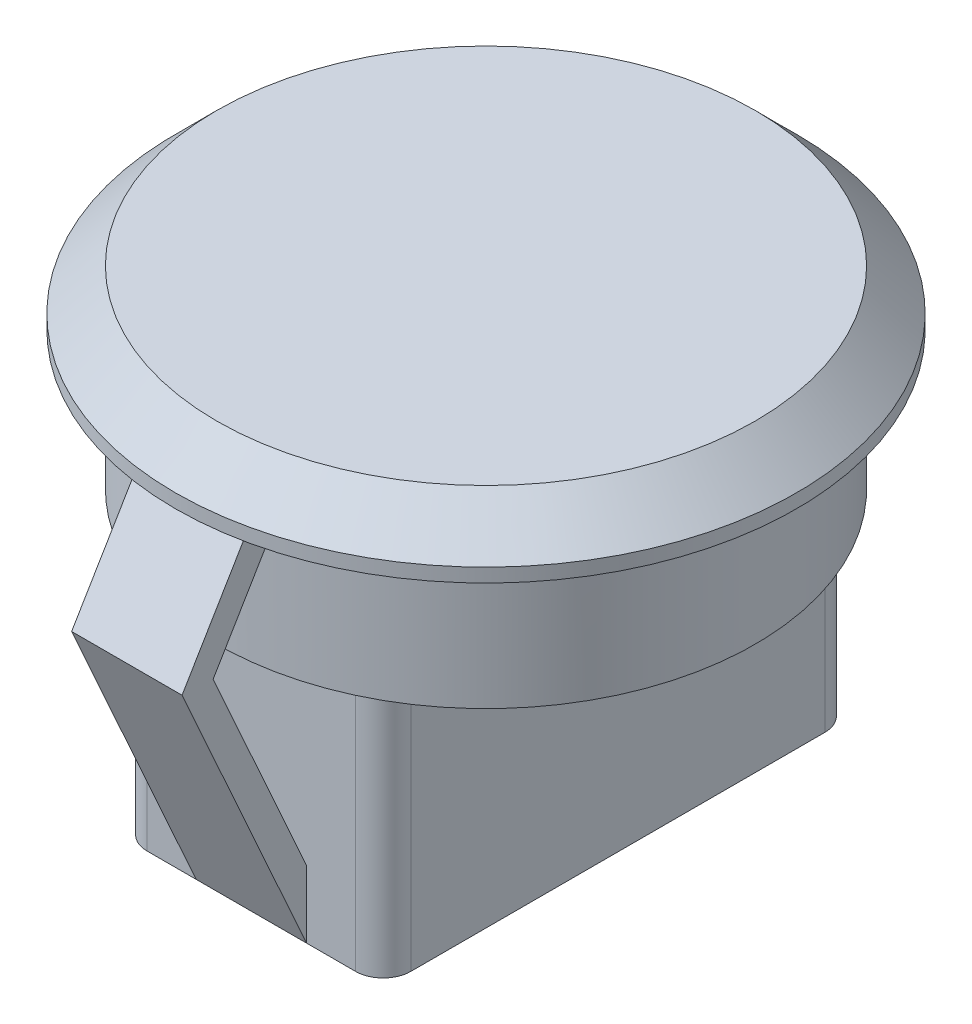
from build123d import *

# Parameters (mm, degrees)
EXTRUDE_1_DEPTH = 5
SKETCH_2_R      = 11.25
EXTRUDE_2_DEPTH = 2
CHAMFER_1_SIZE  = 1.5
SKETCH_3_W      = 9.552486588
SKETCH_3_H      = 17
EXTRUDE_3_DEPTH = 9
FILLET_1_R      = 1
EXTRUDE_4_DEPTH = 2


with BuildPart() as part:
    # Эскиз1 → Бобышка-Вытянуть1 (new body)
    with BuildSketch(Plane(origin=(0, 0, 0), x_dir=(1, 0, 0), z_dir=(0, 1, 0))):
        with BuildLine():
            Line((-10.75, 1), (-9.698582371, 1))
            ThreePointArc((-9.698582371, 1), (9.75, 0), (-9.698582371, -1))
            Line((-9.698582371, -1), (-10.75, -1))
            Line((-10.75, -1), (-10.75, 1))
        make_face()
    extrude(amount=EXTRUDE_1_DEPTH)

    # Эскиз2 → Бобышка-Вытянуть2 (add)
    with BuildSketch(Plane(origin=(0, 5, 0), x_dir=(1, 0, 0), z_dir=(0, 1, 0))):
        Circle(SKETCH_2_R)
    extrude(amount=EXTRUDE_2_DEPTH)

    # Фаска1
    chamfer_1_edges = [part.edges().sort_by_distance(p)[0] for p in [
        (-11.25, 7, 0),
    ]]
    chamfer(chamfer_1_edges, length=CHAMFER_1_SIZE)

    # Эскиз3 → Бобышка-Вытянуть3 (add)
    with BuildSketch(Plane.XZ):
        Rectangle(SKETCH_3_W, SKETCH_3_H)
    extrude(amount=EXTRUDE_3_DEPTH)

    # Скругление1
    fillet_1_edges = [part.edges().sort_by_distance(p)[0] for p in [
        (-4.776243294, -4.5, 8.5),
        (-4.776243294, -4.5, -8.5),
        (4.776243294, -4.5, -8.5),
        (4.776243294, -4.5, 8.5),
    ]]
    fillet(fillet_1_edges, radius=FILLET_1_R)

    # Эскиз4 → Бобышка-Вытянуть4 (add, symmetric)
    with BuildSketch(Plane(origin=(0, 0, 0), x_dir=(0, 0, -1), z_dir=(1, 0, 0))):
        Polygon((-8.5, -9), (-13.010373574, 1.032772808), (-10.70938382, 4.9), (-9.85, 4.388668944), (-11.885037306, 0.968422681), (-7.587929745, -8.589966039), align=None)
        Polygon((11.885037306, 0.968422681), (7.587929745, -8.589966039), (8.5, -9), (13.010373574, 1.032772808), (10.70938382, 4.9), (9.85, 4.388668944), align=None)
    extrude(amount=EXTRUDE_4_DEPTH, both=True)


solid = part.part
